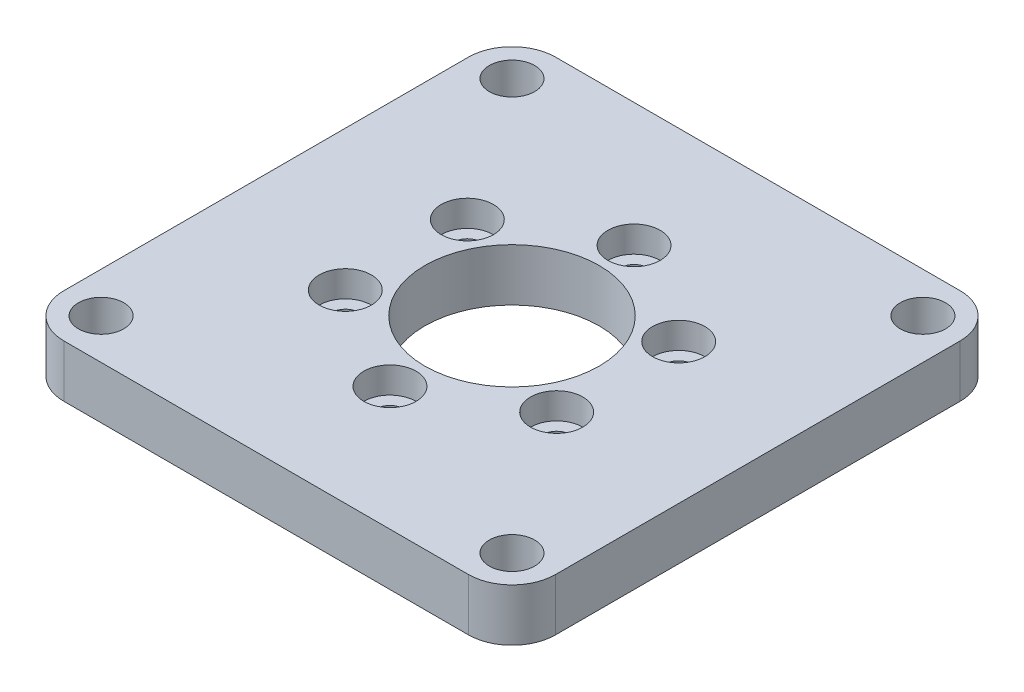
from build123d import *

# Parameters (mm, degrees)
SKETCH1_W           = 56.4
SKETCH1_H           = 56.4
BOSS_EXTRUDE1_DEPTH = 3
FILLET1_R           = 5
SKETCH2_R           = 2.6
CUT_EXTRUDE1_DEPTH  = 7
SKETCH4_R           = 10
CUT_EXTRUDE3_DEPTH  = 7
SKETCH5_R           = 1.55
CUT_EXTRUDE4_DEPTH  = 7
SKETCH6_R           = 3
CUT_EXTRUDE5_DEPTH  = 3
CIRPATTERN1_COUNT   = 6


with BuildPart() as part:
    # Sketch1 → Boss-Extrude1 (new body, symmetric)
    with BuildSketch(Plane(origin=(0, 0, 0), x_dir=(1, 0, 0), z_dir=(0, 1, 0))):
        Rectangle(SKETCH1_W, SKETCH1_H)
    extrude(amount=BOSS_EXTRUDE1_DEPTH, both=True)

    # Fillet1
    fillet1_edges = [part.edges().sort_by_distance(p)[0] for p in [
        (28.2, 0, 28.2),
        (-28.2, 0, 28.2),
        (-28.2, 0, -28.2),
        (28.2, 0, -28.2),
    ]]
    fillet(fillet1_edges, radius=FILLET1_R)

    # Sketch2 → Cut-Extrude1 (cut, through all)
    with BuildSketch(Plane.XZ.offset(3)):
        with Locations((-23.57, 23.57)):
            Circle(SKETCH2_R)
        with Locations((23.57, 23.57)):
            Circle(SKETCH2_R)
        with Locations((23.57, -23.57)):
            Circle(SKETCH2_R)
        with Locations((-23.57, -23.57)):
            Circle(SKETCH2_R)
    extrude(amount=-CUT_EXTRUDE1_DEPTH, mode=Mode.SUBTRACT)

    # Sketch4 → Cut-Extrude3 (cut, through all)
    with BuildSketch(Plane.XZ.offset(3)):
        Circle(SKETCH4_R)
    extrude(amount=-CUT_EXTRUDE3_DEPTH, mode=Mode.SUBTRACT)

    # Sketch5 → Cut-Extrude4 (cut, through all)
    with BuildSketch(Plane(origin=(0, 3, 0), x_dir=(1, 0, 0), z_dir=(0, 1, 0))):
        with Locations((0, 14)):
            Circle(SKETCH5_R)
    cut_extrude4 = extrude(amount=-CUT_EXTRUDE4_DEPTH, mode=Mode.SUBTRACT)

    # Sketch6 → Cut-Extrude5 (cut)
    with BuildSketch(Plane(origin=(0, 3, 0), x_dir=(1, 0, 0), z_dir=(0, 1, 0))):
        with Locations((0, 14)):
            Circle(SKETCH6_R)
    cut_extrude5 = extrude(amount=-CUT_EXTRUDE5_DEPTH, mode=Mode.SUBTRACT)

    # CirPattern1: Cut-Extrude4, Cut-Extrude5 ×6 about axis
    cirpattern1_axis = Axis((0, 0, 0), (0, 1, 0))
    for i in range(1, CIRPATTERN1_COUNT):
        add(cut_extrude4.rotate(cirpattern1_axis, i * 360 / CIRPATTERN1_COUNT), mode=Mode.SUBTRACT)
        add(cut_extrude5.rotate(cirpattern1_axis, i * 360 / CIRPATTERN1_COUNT), mode=Mode.SUBTRACT)


solid = part.part
